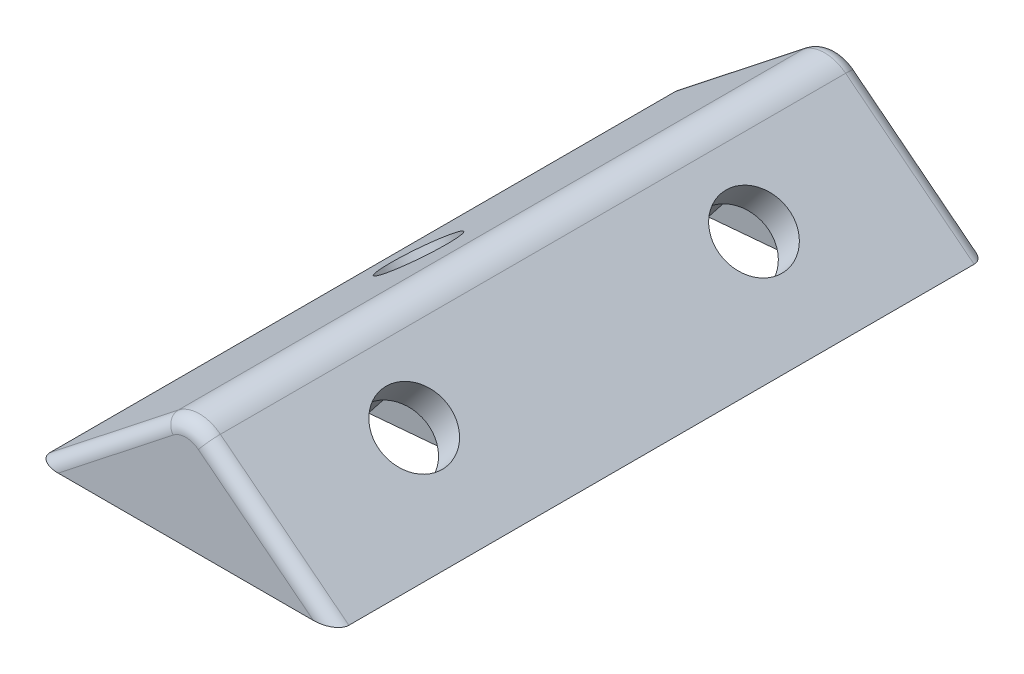
from build123d import *

# Parameters (mm, degrees)
BOSS_EXTRUDE3_DEPTH = 48
SKETCH4_R           = 2.625
CUT_EXTRUDE2_DEPTH  = 14.608970631
SKETCH5_R           = 2.625
CUT_EXTRUDE3_DEPTH  = 14.608970631
FILLET2_R           = 2.5
CUT_EXTRUDE4_DEPTH  = 12.5
CUT_EXTRUDE6_DEPTH  = 12.5
FILLET3_R           = 1
FILLET4_R           = 1


with BuildPart() as part:
    # Sketch2 → Boss-Extrude3 (new body)
    with BuildSketch(Plane.XY):
        Polygon((0, 2.309401077), (-11, -6.350852961), (11, -6.350852961), align=None)
    extrude(amount=BOSS_EXTRUDE3_DEPTH)

    # Sketch4 → Cut-Extrude2 (cut, through all)
    with BuildSketch(Plane(origin=(-1.12244898, 1.425701685, 0), x_dir=(0.785714286, 0.618589574, 0), z_dir=(-0.618589574, 0.785714286, 0))):
        with Locations((-7.321428571, -24)):
            Circle(SKETCH4_R)
    extrude(amount=-CUT_EXTRUDE2_DEPTH, mode=Mode.SUBTRACT)

    # Sketch5 → Cut-Extrude3 (cut, through all)
    with BuildSketch(Plane(origin=(1.12244898, 1.425701685, 0), x_dir=(0.785714286, -0.618589574, 0), z_dir=(0.618589574, 0.785714286, 0))):
        with Locations((5.321428571, -11.5)):
            Circle(SKETCH5_R)
        with Locations((5.321428571, -36.5)):
            Circle(SKETCH5_R)
    extrude(amount=-CUT_EXTRUDE3_DEPTH, mode=Mode.SUBTRACT)

    # Fillet2
    fillet2_edges = [part.edges().sort_by_distance(p)[0] for p in [
        (0, 2.309401077, 24),
    ]]
    fillet(fillet2_edges, radius=FILLET2_R)

    # Sketch6 → Cut-Extrude4 (cut)
    with BuildSketch(Plane(origin=(-8.156394632, -10.360012601, 0), x_dir=(0.785714286, -0.618589574, 0), z_dir=(0.618589574, 0.785714286, 0))):
        Polygon((7.160320357, -7.200177097), (2.517118598, -7.757561547), (0.678226812, -12.05738445), (3.482536786, -15.799822903), (8.125738545, -15.242438453), (9.96463033, -10.94261555), align=None)
        Polygon((7.160320357, -32.200177097), (2.517118598, -32.757561547), (0.678226812, -37.05738445), (3.482536786, -40.799822903), (8.125738545, -40.242438453), (9.96463033, -35.94261555), align=None)
    extrude(amount=CUT_EXTRUDE4_DEPTH, mode=Mode.SUBTRACT)

    # Sketch7 → Cut-Extrude6 (cut)
    with BuildSketch(Plane(origin=(8.156394632, -10.360012601, 0), x_dir=(0.785714286, 0.618589574, 0), z_dir=(-0.618589574, 0.785714286, 0))):
        Polygon((-7.321428571, -19.32346282), (-11.371428571, -21.66173141), (-11.371428571, -26.33826859), (-7.321428571, -28.67653718), (-3.271428571, -26.33826859), (-3.271428571, -21.66173141), align=None)
    extrude(amount=CUT_EXTRUDE6_DEPTH, mode=Mode.SUBTRACT)

    # Fillet3
    fillet3_edges = [part.edges().sort_by_distance(p)[0] for p in [
        (-6.273236968, -2.629492176, 0),
        (0, 1.627582895, 0),
        (6.273236968, -2.629492176, 0),
    ]]
    fillet(fillet3_edges, radius=FILLET3_R)

    # Fillet4
    fillet4_edges = [part.edges().sort_by_distance(p)[0] for p in [
        (-6.273236968, -2.629492176, 48),
        (0, 1.627582895, 48),
        (6.273236968, -2.629492176, 48),
    ]]
    fillet(fillet4_edges, radius=FILLET4_R)


solid = part.part
